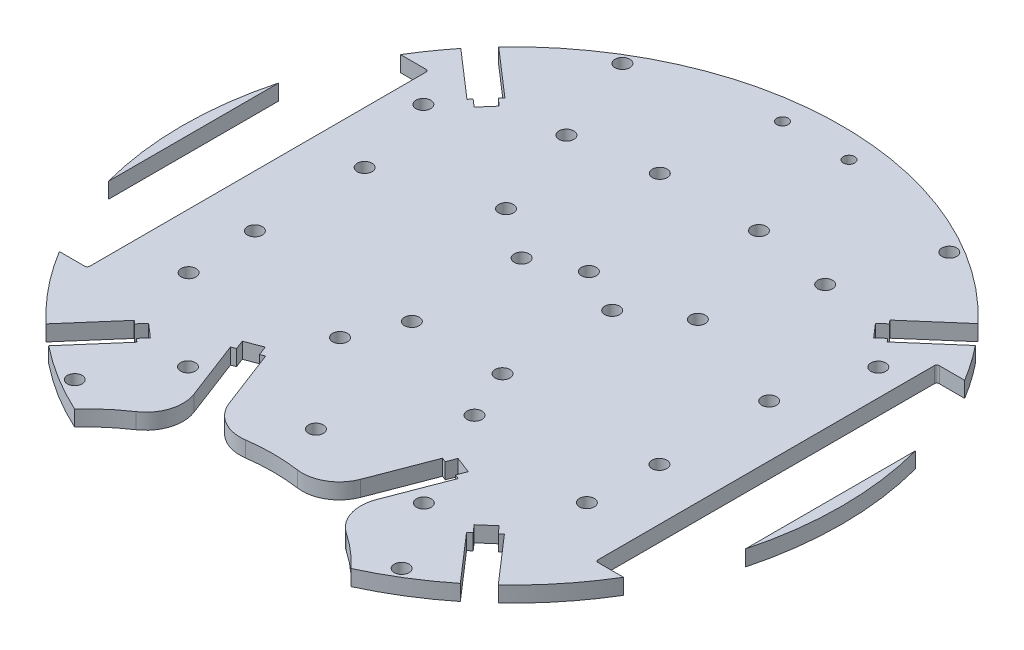
from build123d import *

# Parameters (mm, degrees)
SKETCH1_R           = 1.5
SKETCH1_R_2         = 1.143
BOSS_EXTRUDE1_DEPTH = 3.175
SKETCH2_R           = 80.935958151
SKETCH2_R_2         = 66.67
CUT_EXTRUDE1_DEPTH  = 10


with BuildPart() as part:
    # Sketch1 → Boss-Extrude1 (new body)
    with BuildSketch(Plane(origin=(0, 0, 0), x_dir=(1, 0, 0), z_dir=(0, 1, 0))):
        with BuildLine():
            Line((-34.051680938, -41.91563352), (-33.334715323, -42.538882221))
            Line((-33.334715323, -42.538882221), (-41.689597364, -52.150074566))
            ThreePointArc((-41.689597364, -52.150074566), (-43.455441558, -58.16401884), (-40.038526417, -63.418580892))
            ThreePointArc((-40.038526417, -63.418580892), (-37.791118701, -64.782955685), (-35.49727084, -66.067721036))
            ThreePointArc((-35.49727084, -66.067721036), (-33.357679643, -66.33740492), (-31.589980006, -65.102164912))
            ThreePointArc((-31.589980006, -65.102164912), (-26.929242455, -59.449715082), (-21.272807595, -54.79381471))
            ThreePointArc((-21.272807595, -54.79381471), (-18.309924074, -50.834725832), (-18.455489673, -45.891864903))
            Line((-18.455489673, -45.891864903), (-23.038155213, -33.91632612))
            Line((-23.038155213, -33.91632612), (-22.143006255, -33.573780506))
            Line((-22.143006255, -33.573780506), (-22.857795969, -31.705873746))
            Line((-22.857795969, -31.705873746), (-19.4955638, -30.419252261))
            Line((-19.4955638, -30.419252261), (-18.780774086, -32.287159021))
            Line((-18.780774086, -32.287159021), (-17.885625128, -31.944613407))
            Line((-17.885625128, -31.944613407), (-13.302959587, -43.920152189))
            ThreePointArc((-13.302959587, -43.920152189), (-10.111582251, -47.697475872), (-5.262593756, -48.667204744))
            ThreePointArc((-5.262593756, -48.667204744), (0, -48.302004425), (5.262593756, -48.667204744))
            ThreePointArc((5.262593756, -48.667204744), (10.111582251, -47.697475872), (13.302959587, -43.920152189))
            Line((13.302959587, -43.920152189), (17.885625128, -31.944613407))
            Line((17.885625128, -31.944613407), (18.780774086, -32.287159021))
            Line((18.780774086, -32.287159021), (19.4955638, -30.419252261))
            Line((19.4955638, -30.419252261), (22.857795969, -31.705873746))
            Line((22.857795969, -31.705873746), (22.143006255, -33.573780506))
            Line((22.143006255, -33.573780506), (23.038155213, -33.91632612))
            Line((23.038155213, -33.91632612), (18.455489673, -45.891864903))
            ThreePointArc((18.455489673, -45.891864903), (18.309924074, -50.834725832), (21.272807595, -54.79381471))
            ThreePointArc((21.272807595, -54.79381471), (26.929242455, -59.449715082), (31.589980006, -65.102164912))
            ThreePointArc((31.589980006, -65.102164912), (33.357679643, -66.33740492), (35.49727084, -66.067721036))
            ThreePointArc((35.49727084, -66.067721036), (37.791118701, -64.782955685), (40.038526417, -63.418580892))
            ThreePointArc((40.038526417, -63.418580892), (43.455441558, -58.16401884), (41.689597364, -52.150074566))
            Line((41.689597364, -52.150074566), (33.334715323, -42.538882221))
            Line((33.334715323, -42.538882221), (34.051680938, -41.91563352))
            Line((34.051680938, -41.91563352), (32.73956288, -40.40621436))
            Line((32.73956288, -40.40621436), (35.456517369, -38.044401855))
            Line((35.456517369, -38.044401855), (36.768635427, -39.553821016))
            Line((36.768635427, -39.553821016), (37.436380929, -38.973358707))
            Line((37.436380929, -38.973358707), (45.791262658, -48.584550695))
            ThreePointArc((45.791262658, -48.584550695), (51.498800201, -51.177786739), (57.181686783, -48.530966368))
            ThreePointArc((57.181686783, -48.530966368), (74.817303766, -5.23173558), (63.379403673, 40.100513589))
            ThreePointArc((63.379403673, 40.100513589), (58.120188747, 43.512480309), (52.107287817, 41.738817166))
            Line((52.107287817, 41.738817166), (42.496095829, 33.383935436))
            Line((42.496095829, 33.383935436), (41.91563352, 34.051680938))
            Line((41.91563352, 34.051680938), (40.40621436, 32.73956288))
            Line((40.40621436, 32.73956288), (38.044401855, 35.456517369))
            Line((38.044401855, 35.456517369), (39.553821016, 36.768635427))
            Line((39.553821016, 36.768635427), (38.930572315, 37.485601042))
            Line((38.930572315, 37.485601042), (48.541764661, 45.840483082))
            ThreePointArc((48.541764661, 45.840483082), (51.127403054, 51.550142051), (48.475034791, 57.229109743))
            ThreePointArc((48.475034791, 57.229109743), (0, 75), (-48.475034791, 57.229109743))
            ThreePointArc((-48.475034791, 57.229109743), (-51.127403054, 51.550142051), (-48.541764661, 45.840483082))
            Line((-48.541764661, 45.840483082), (-38.930572315, 37.485601042))
            Line((-38.930572315, 37.485601042), (-39.553821016, 36.768635427))
            Line((-39.553821016, 36.768635427), (-38.044401855, 35.456517369))
            Line((-38.044401855, 35.456517369), (-40.40621436, 32.73956288))
            Line((-40.40621436, 32.73956288), (-41.91563352, 34.051680938))
            Line((-41.91563352, 34.051680938), (-42.496095829, 33.383935436))
            Line((-42.496095829, 33.383935436), (-52.107287817, 41.738817166))
            ThreePointArc((-52.107287817, 41.738817166), (-58.120188726, 43.512480312), (-63.379403651, 40.100513624))
            ThreePointArc((-63.379403651, 40.100513624), (-74.817303772, -5.231735496), (-57.181686866, -48.530966271))
            ThreePointArc((-57.181686866, -48.530966271), (-51.498800265, -51.177786738), (-45.791262658, -48.584550695))
            Line((-45.791262658, -48.584550695), (-37.436380929, -38.973358707))
            Line((-37.436380929, -38.973358707), (-36.768635427, -39.553821016))
            Line((-36.768635427, -39.553821016), (-35.456517369, -38.044401855))
            Line((-35.456517369, -38.044401855), (-32.73956288, -40.40621436))
            Line((-32.73956288, -40.40621436), (-34.051680938, -41.91563352))
        make_face()
        with Locations((-33.059737365, -55.383244446)):
            Circle(SKETCH1_R, mode=Mode.SUBTRACT)
        with Locations((-23.852486199, -41.694616163)):
            Circle(SKETCH1_R, mode=Mode.SUBTRACT)
        with Locations((0, -39.659190322)):
            Circle(SKETCH1_R, mode=Mode.SUBTRACT)
        with Locations((-40.277379234, -25.14022965)):
            Circle(SKETCH1_R, mode=Mode.SUBTRACT)
        with BuildLine():
            Line((-51.910067426, -34.5), (-63.910067426, -34.5))
            ThreePointArc((-63.910067426, -34.5), (-64.263620817, -34.353553391), (-64.410067426, -34))
            Line((-64.410067426, -34), (-64.410067426, 34))
            ThreePointArc((-64.410067426, 34), (-64.263620817, 34.353553391), (-63.910067426, 34.5))
            Line((-63.910067426, 34.5), (-51.910067426, 34.5))
            ThreePointArc((-51.910067426, 34.5), (-51.556514035, 34.353553391), (-51.410067426, 34))
            Line((-51.410067426, 34), (-51.410067426, -34))
            ThreePointArc((-51.410067426, -34), (-51.556514035, -34.353553391), (-51.910067426, -34.5))
        make_face(mode=Mode.SUBTRACT)
        with Locations((-40.910067426, -11.1)):
            Circle(SKETCH1_R, mode=Mode.SUBTRACT)
        with Locations((-13.608916499, -21.183093811)):
            Circle(SKETCH1_R, mode=Mode.SUBTRACT)
        with Locations((-9.160067426, -11.1)):
            Circle(SKETCH1_R, mode=Mode.SUBTRACT)
        with Locations((33.059737365, -55.383244446)):
            Circle(SKETCH1_R, mode=Mode.SUBTRACT)
        with Locations((23.852486199, -41.694616163)):
            Circle(SKETCH1_R, mode=Mode.SUBTRACT)
        with Locations((13.608916499, -21.183093811)):
            Circle(SKETCH1_R, mode=Mode.SUBTRACT)
        with Locations((9.160067426, -11.1)):
            Circle(SKETCH1_R, mode=Mode.SUBTRACT)
        with Locations((40.277379234, -25.14022965)):
            Circle(SKETCH1_R, mode=Mode.SUBTRACT)
        with Locations((40.910067426, -11.1)):
            Circle(SKETCH1_R, mode=Mode.SUBTRACT)
        with BuildLine():
            ThreePointArc((51.910067426, -34.5), (51.556514035, -34.353553391), (51.410067426, -34))
            Line((51.410067426, -34), (51.410067426, 34))
            ThreePointArc((51.410067426, 34), (51.556514035, 34.353553391), (51.910067426, 34.5))
            Line((51.910067426, 34.5), (63.910067426, 34.5))
            ThreePointArc((63.910067426, 34.5), (64.263620817, 34.353553391), (64.410067426, 34))
            Line((64.410067426, 34), (64.410067426, -34))
            ThreePointArc((64.410067426, -34), (64.263620817, -34.353553391), (63.910067426, -34.5))
            Line((63.910067426, -34.5), (51.910067426, -34.5))
        make_face(mode=Mode.SUBTRACT)
        with Locations((-40.910067426, 11.1)):
            Circle(SKETCH1_R, mode=Mode.SUBTRACT)
        with Locations((-46.011477091, 28.075890486)):
            Circle(SKETCH1_R, mode=Mode.SUBTRACT)
        with Locations((-19.397913834, 18.186588214)):
            Circle(SKETCH1_R, mode=Mode.SUBTRACT)
        with Locations((-9.160067426, 11.1)):
            Circle(SKETCH1_R, mode=Mode.SUBTRACT)
        with Locations((0, 15.543589551)):
            Circle(SKETCH1_R, mode=Mode.SUBTRACT)
        with Locations((-26.163250867, 37.1696126)):
            Circle(SKETCH1_R, mode=Mode.SUBTRACT)
        with Locations((-33.059737365, 55.383244446)):
            Circle(SKETCH1_R, mode=Mode.SUBTRACT)
        with Locations((-10.027203595, 39.91869143)):
            Circle(SKETCH1_R, mode=Mode.SUBTRACT)
        with Locations((-6.731, 61.422565207)):
            Circle(SKETCH1_R_2, mode=Mode.SUBTRACT)
        with Locations((9.160067426, 11.1)):
            Circle(SKETCH1_R, mode=Mode.SUBTRACT)
        with Locations((19.397913834, 18.186588214)):
            Circle(SKETCH1_R, mode=Mode.SUBTRACT)
        with Locations((26.163250867, 37.1696126)):
            Circle(SKETCH1_R, mode=Mode.SUBTRACT)
        with Locations((40.910067426, 11.1)):
            Circle(SKETCH1_R, mode=Mode.SUBTRACT)
        with Locations((46.011477091, 28.075890486)):
            Circle(SKETCH1_R, mode=Mode.SUBTRACT)
        with Locations((10.027203595, 39.91869143)):
            Circle(SKETCH1_R, mode=Mode.SUBTRACT)
        with Locations((33.059737365, 55.383244446)):
            Circle(SKETCH1_R, mode=Mode.SUBTRACT)
        with Locations((6.731, 61.422565207)):
            Circle(SKETCH1_R_2, mode=Mode.SUBTRACT)
    extrude(amount=BOSS_EXTRUDE1_DEPTH)

    # Sketch2 → Cut-Extrude1 (cut)
    with BuildSketch(Plane(origin=(0, 3.175, 0), x_dir=(1, 0, 0), z_dir=(0, 1, 0))):
        Circle(SKETCH2_R)
        Circle(SKETCH2_R_2, mode=Mode.SUBTRACT)
    extrude(amount=-CUT_EXTRUDE1_DEPTH, mode=Mode.SUBTRACT)


solid = part.part
